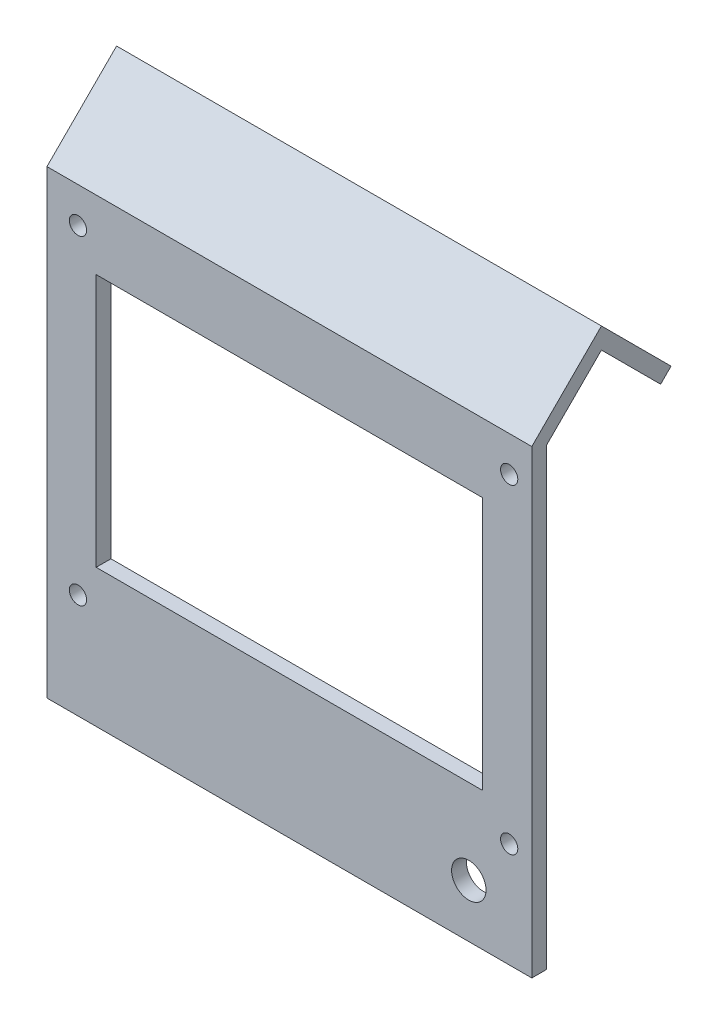
from build123d import *

# Parameters (mm, degrees)
SKETCH1_W           = 98.5
SKETCH1_H           = 93.5
SKETCH1_W_2         = 78.5
SKETCH1_H_2         = 51.5
BOSS_EXTRUDE1_DEPTH = 3
CUT_EXTRUDE1_REACH  = 5
SKETCH2_R           = 3.5
SKETCH2_R_2         = 1.75
BOSS_EXTRUDE4_DEPTH = 98.5
BOSS_EXTRUDE5_DEPTH = 98.5


with BuildPart() as part:
    # Sketch1 → Boss-Extrude1 (new body)
    with BuildSketch(Plane.XY):
        with Locations((49.25, 46.75)):
            Rectangle(SKETCH1_W, SKETCH1_H)
        with Locations((49.25, 53.75)):
            Rectangle(SKETCH1_W_2, SKETCH1_H_2, mode=Mode.SUBTRACT)
    extrude(amount=BOSS_EXTRUDE1_DEPTH)

    # Sketch2 → Cut-Extrude1 (cut, up to next)
    with BuildSketch(Plane.XY.offset(3), mode=Mode.PRIVATE) as cut_extrude1_sk1:
        with Locations((85.7, 10.8)):
            Circle(SKETCH2_R)
    cut_extrude1_tool1 = extrude(cut_extrude1_sk1.sketch, amount=-CUT_EXTRUDE1_REACH, mode=Mode.PRIVATE) & part.part
    add(cut_extrude1_tool1.solids().sort_by_distance((85.7, 10.8, 3))[0], mode=Mode.SUBTRACT)
    # Sketch2 → Cut-Extrude1 (cut, up to next)
    with BuildSketch(Plane.XY.offset(3), mode=Mode.PRIVATE) as cut_extrude1_sk2:
        with Locations((93.9, 86.3)):
            Circle(SKETCH2_R_2)
    cut_extrude1_tool2 = extrude(cut_extrude1_sk2.sketch, amount=-CUT_EXTRUDE1_REACH, mode=Mode.PRIVATE) & part.part
    add(cut_extrude1_tool2.solids().sort_by_distance((93.9, 86.3, 3))[0], mode=Mode.SUBTRACT)
    # Sketch2 → Cut-Extrude1 (cut, up to next)
    with BuildSketch(Plane.XY.offset(3), mode=Mode.PRIVATE) as cut_extrude1_sk3:
        with Locations((93.9, 21.3)):
            Circle(SKETCH2_R_2)
    cut_extrude1_tool3 = extrude(cut_extrude1_sk3.sketch, amount=-CUT_EXTRUDE1_REACH, mode=Mode.PRIVATE) & part.part
    add(cut_extrude1_tool3.solids().sort_by_distance((93.9, 21.3, 3))[0], mode=Mode.SUBTRACT)
    # Sketch2 → Cut-Extrude1 (cut, up to next)
    with BuildSketch(Plane.XY.offset(3), mode=Mode.PRIVATE) as cut_extrude1_sk4:
        with Locations((6.3, 21.3)):
            Circle(SKETCH2_R_2)
    cut_extrude1_tool4 = extrude(cut_extrude1_sk4.sketch, amount=-CUT_EXTRUDE1_REACH, mode=Mode.PRIVATE) & part.part
    add(cut_extrude1_tool4.solids().sort_by_distance((6.3, 21.3, 3))[0], mode=Mode.SUBTRACT)
    # Sketch2 → Cut-Extrude1 (cut, up to next)
    with BuildSketch(Plane.XY.offset(3), mode=Mode.PRIVATE) as cut_extrude1_sk5:
        with Locations((6.3, 86.3)):
            Circle(SKETCH2_R_2)
    cut_extrude1_tool5 = extrude(cut_extrude1_sk5.sketch, amount=-CUT_EXTRUDE1_REACH, mode=Mode.PRIVATE) & part.part
    add(cut_extrude1_tool5.solids().sort_by_distance((6.3, 86.3, 3))[0], mode=Mode.SUBTRACT)

    # Sketch5 → Boss-Extrude4 (add)
    with BuildSketch(Plane.ZY):
        Polygon((3, 93.5), (-11.142135624, 107.642135624), (-13.263455967, 105.52081528), (0.878679656, 91.378679656), align=None)
    extrude(amount=-BOSS_EXTRUDE4_DEPTH)

    # Sketch6 → Boss-Extrude5 (add)
    with BuildSketch(Plane.ZY):
        Polygon((-11.142135624, 107.642135624), (-25.284271247, 93.5), (-23.162950904, 91.378679656), (-9.02081528, 105.52081528), align=None)
    extrude(amount=-BOSS_EXTRUDE5_DEPTH)


solid = part.part
